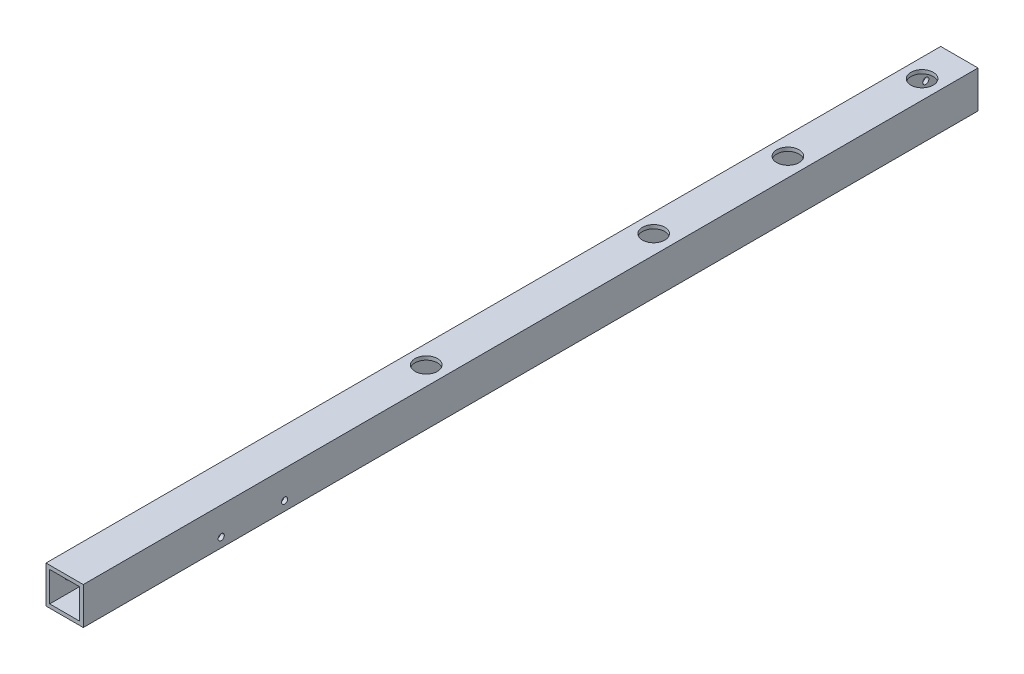
from build123d import *

# Parameters (mm, degrees)
SKETCH_1_W               = 20
SKETCH_1_H               = 20
SKETCH_1_W_2             = 16
SKETCH_1_H_2             = 16
EXTRUDE_1_DEPTH          = 560
SKETCH_3_R               = 2.2
CUT_EXTRUDE_2_DEPTH      = 560
SKETCH_4_R               = 2.2
CUT_EXTRUDE_3_DEPTH      = 560
SKETCH_7_W               = 41.109335544
SKETCH_7_H               = 41.63539172
CUT_EXTRUDE_7_DEPTH      = 40
SKETCH_8_W               = 53.430317452
SKETCH_8_H               = 33.679555816
CUT_EXTRUDE_8_DEPTH      = 40
SKETCH_9_R               = 1
CUT_EXTRUDE_9_DEPTH      = 10
SKETCH_10_R              = 1
CUT_EXTRUDE_10_DEPTH     = 10
SKETCH_11_R              = 2.1
CUT_EXTRUDE_11_DEPTH     = 21
SKETCH_12_R              = 6
CUT_EXTRUDE_12_DEPTH     = 10
SKETCH_15_R              = 2.1
CUT_EXTRUDE_16_DEPTH     = 21
SKETCH_16_R              = 6
CUT_EXTRUDE_17_DEPTH     = 10
M4X0_7_6_D               = 3.3
M4X0_7_6_DEPTH           = 11.5
M4X0_7_6_TIP             = 0.991420021
M4X0_7_7_D               = 3.3
M4X0_7_7_DEPTH           = 11.5
M4X0_7_7_TIP             = 0.991420021
M4X0_7_7_ON_FACE_2_D     = 3.3
M4X0_7_7_ON_FACE_2_DEPTH = 11.5
M4X0_7_7_ON_FACE_2_TIP   = 0.991420021
SKETCH_26_R              = 1
CUT_EXTRUDE_18_DEPTH     = 10
M4X0_7_9_D               = 3.3
M4X0_7_9_DEPTH           = 11.5
M4X0_7_9_TIP             = 0.991420021


with BuildPart() as part:
    # ｽｹｯﾁ1 → ﾎﾞｽ - 押し出し1 (new body)
    with BuildSketch(Plane.XY):
        Rectangle(SKETCH_1_W, SKETCH_1_H)
        Rectangle(SKETCH_1_W_2, SKETCH_1_H_2, mode=Mode.SUBTRACT)
    extrude(amount=EXTRUDE_1_DEPTH)

    # ｽｹｯﾁ3 → ｶｯﾄ - 押し出し2 (cut)
    with BuildSketch(Plane(origin=(10, 0, 0), x_dir=(0, 0, -1), z_dir=(1, 0, 0))):
        with Locations((-530, 0)):
            Circle(SKETCH_3_R)
        with Locations((-30, 0)):
            Circle(SKETCH_3_R)
    extrude(amount=-CUT_EXTRUDE_2_DEPTH, mode=Mode.SUBTRACT)

    # ｽｹｯﾁ4 → ｶｯﾄ - 押し出し3 (cut)
    with BuildSketch(Plane(origin=(0, 10, 0), x_dir=(1, 0, 0), z_dir=(0, 1, 0))):
        with Locations((0, -550)):
            Circle(SKETCH_4_R)
        with Locations((0, -10)):
            Circle(SKETCH_4_R)
    extrude(amount=-CUT_EXTRUDE_3_DEPTH, mode=Mode.SUBTRACT)

    # ｽｹｯﾁ7 → ｶｯﾄ - 押し出し7 (cut)
    with BuildSketch(Plane(origin=(0, 0, 0), x_dir=(-1, 0, 0), z_dir=(0, 0, -1))):
        Rectangle(SKETCH_7_W, SKETCH_7_H)
    extrude(amount=-CUT_EXTRUDE_7_DEPTH, mode=Mode.SUBTRACT)

    # ｽｹｯﾁ8 → ｶｯﾄ - 押し出し8 (cut)
    with BuildSketch(Plane.XY.offset(560)):
        Rectangle(SKETCH_8_W, SKETCH_8_H)
    extrude(amount=-CUT_EXTRUDE_8_DEPTH, mode=Mode.SUBTRACT)

    # ｽｹｯﾁ9 → ｶｯﾄ - 押し出し9 (cut)
    with BuildSketch(Plane.ZY.offset(10)):
        with Locations((510, 0)):
            Circle(SKETCH_9_R)
        with Locations((490, 0)):
            Circle(SKETCH_9_R)
    extrude(amount=-CUT_EXTRUDE_9_DEPTH, mode=Mode.SUBTRACT)

    # ｽｹｯﾁ10 → ｶｯﾄ - 押し出し10 (cut)
    with BuildSketch(Plane.ZY.offset(10)):
        with Locations((50, 0)):
            Circle(SKETCH_10_R)
        with Locations((70, 0)):
            Circle(SKETCH_10_R)
    extrude(amount=-CUT_EXTRUDE_10_DEPTH, mode=Mode.SUBTRACT)

    # ｽｹｯﾁ11 → ｶｯﾄ - 押し出し11 (cut, through all)
    with BuildSketch(Plane(origin=(0, 10, 0), x_dir=(1, 0, 0), z_dir=(0, 1, 0))):
        with Locations((0, -60)):
            Circle(SKETCH_11_R)
        with Locations((0, -132)):
            Circle(SKETCH_11_R)
        with Locations((0, -204)):
            Circle(SKETCH_11_R)
    extrude(amount=-CUT_EXTRUDE_11_DEPTH, mode=Mode.SUBTRACT)

    # ｽｹｯﾁ12 → ｶｯﾄ - 押し出し12 (cut)
    with BuildSketch(Plane(origin=(0, 10, 0), x_dir=(1, 0, 0), z_dir=(0, 1, 0))):
        with Locations((0, -60)):
            Circle(SKETCH_12_R)
        with Locations((0, -132)):
            Circle(SKETCH_12_R)
        with Locations((0, -204)):
            Circle(SKETCH_12_R)
    extrude(amount=-CUT_EXTRUDE_12_DEPTH, mode=Mode.SUBTRACT)

    # ｽｹｯﾁ15 → ｶｯﾄ - 押し出し16 (cut, through all)
    with BuildSketch(Plane(origin=(0, 10, 0), x_dir=(1, 0, 0), z_dir=(0, 1, 0))):
        with Locations((0, -326)):
            Circle(SKETCH_15_R)
    extrude(amount=-CUT_EXTRUDE_16_DEPTH, mode=Mode.SUBTRACT)

    # ｽｹｯﾁ16 → ｶｯﾄ - 押し出し17 (cut)
    with BuildSketch(Plane(origin=(0, 10, 0), x_dir=(1, 0, 0), z_dir=(0, 1, 0))):
        with Locations((0, -326)):
            Circle(SKETCH_16_R)
    extrude(amount=-CUT_EXTRUDE_17_DEPTH, mode=Mode.SUBTRACT)

    # M4x0.7 ねじ穴6
    with Locations(Plane(origin=(-10, 0, 70), x_dir=(0, -1, 0), z_dir=(-1, 0, 0))):
        with Locations((0, 0), (0, -20)):
            Hole(M4X0_7_6_D / 2, depth=M4X0_7_6_DEPTH)
            with Locations((0, 0, -(M4X0_7_6_DEPTH + M4X0_7_6_TIP / 2))):  # 118° drill point
                Cone(0, M4X0_7_6_D / 2, M4X0_7_6_TIP, mode=Mode.SUBTRACT)

    # M4x0.7 ねじ穴7
    with Locations(Plane(origin=(-8, 0, 490), x_dir=(0, 0, 1), z_dir=(1, 0, 0))):
        with Locations((0, 0)):
            Hole(M4X0_7_7_D / 2, depth=M4X0_7_7_DEPTH)
            with Locations((0, 0, -(M4X0_7_7_DEPTH + M4X0_7_7_TIP / 2))):  # 118° drill point
                Cone(0, M4X0_7_7_D / 2, M4X0_7_7_TIP, mode=Mode.SUBTRACT)

    # M4x0.7 ねじ穴7 on face 2
    with Locations(Plane(origin=(-10, 0, 510), x_dir=(0, 0, 1), z_dir=(1, 0, 0))):
        with Locations((0, 0)):
            Hole(M4X0_7_7_ON_FACE_2_D / 2, depth=M4X0_7_7_ON_FACE_2_DEPTH)
            with Locations((0, 0, -(M4X0_7_7_ON_FACE_2_DEPTH + M4X0_7_7_ON_FACE_2_TIP / 2))):  # 118° drill point
                Cone(0, M4X0_7_7_ON_FACE_2_D / 2, M4X0_7_7_ON_FACE_2_TIP, mode=Mode.SUBTRACT)

    # ｽｹｯﾁ26 → ｶｯﾄ - 押し出し18 (cut)
    with BuildSketch(Plane(origin=(10, 0, 0), x_dir=(0, 0, -1), z_dir=(1, 0, 0))):
        with Locations((-446, -5)):
            Circle(SKETCH_26_R)
        with Locations((-412, -5)):
            Circle(SKETCH_26_R)
    extrude(amount=-CUT_EXTRUDE_18_DEPTH, mode=Mode.SUBTRACT)

    # M4x0.7 ねじ穴9
    with Locations(Plane(origin=(10, -5, 446), x_dir=(0, 0, 1), z_dir=(1, 0, 0))):
        with Locations((0, 0), (-34, 0)):
            Hole(M4X0_7_9_D / 2, depth=M4X0_7_9_DEPTH)
            with Locations((0, 0, -(M4X0_7_9_DEPTH + M4X0_7_9_TIP / 2))):  # 118° drill point
                Cone(0, M4X0_7_9_D / 2, M4X0_7_9_TIP, mode=Mode.SUBTRACT)


solid = part.part
